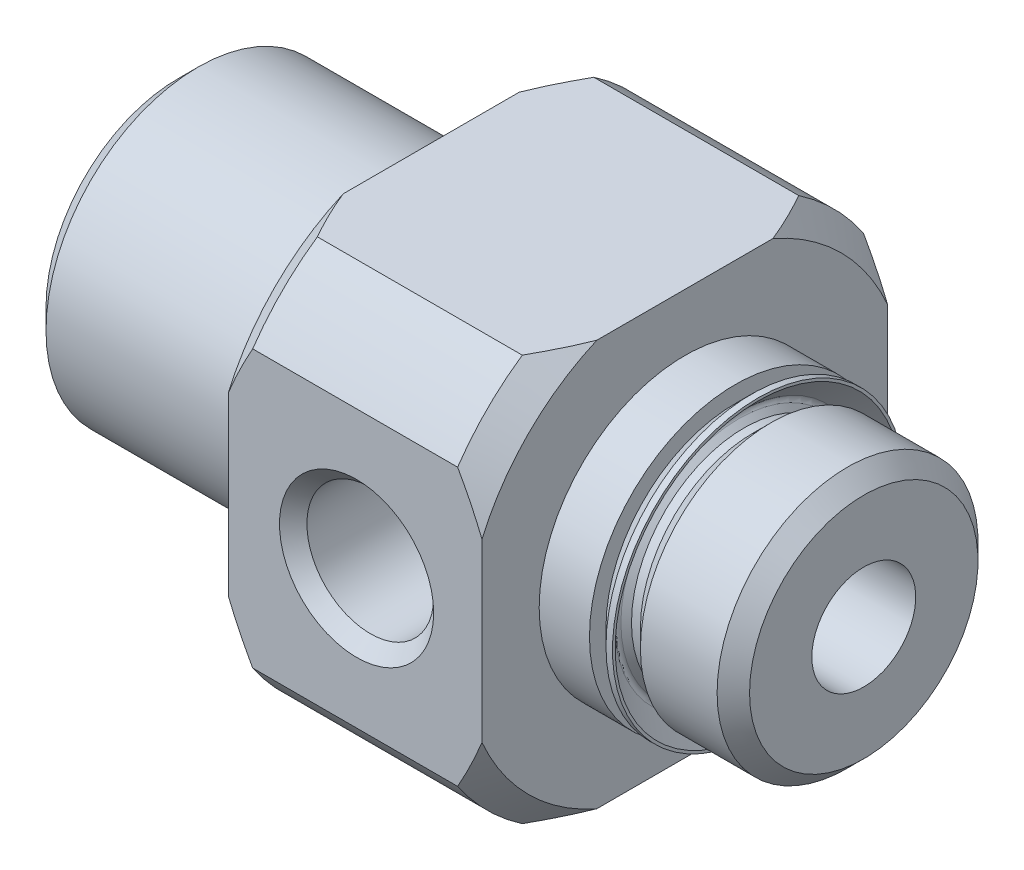
from build123d import *

# Parameters (mm, degrees)
SKETCH3_W          = 1.5748
SKETCH3_H          = 4.5593
HOLE1_D            = 3.2512
HOLE1_DEPTH        = 21.463
HOLE1_CSINK_D      = 4.0132
HOLE1_CSINK_ANGLE  = 90
SKETCH6_W          = 25.4
SKETCH6_H          = 25.4
SKETCH6_W_2        = 12.7
SKETCH6_H_2        = 12.7
CUT_EXTRUDE1_DEPTH = 21.463
HOLE2_D            = 3.96748
HOLE2_DEPTH        = 6.35
HOLE2_CSINK_D      = 4.826
HOLE2_CSINK_ANGLE  = 90


with BuildPart() as part:
    # Sketch1 → Revolve1 (revolve)
    with BuildSketch(Plane.XY):
        Polygon((0, 0), (0, 4.13258), (0.62992, 4.7625), (7.9248, 4.7625), (7.9248, 0), align=None)
    revolve(axis=Axis((7.9248, 0, 0), (-1, 0, 0)))

    # Sketch2 → Revolve2 (revolve)
    with BuildSketch(Plane.XY):
        Polygon((7.9248, 0), (7.9248, 6.9215), (8.6868, 7.6835), (15.1003, 7.6835), (15.8623, 6.9215), (15.8623, 3.52425), (17.9959, 3.52425), (18.5547, 4.08305), (20.955, 4.08305), (21.463, 3.57505), (21.463, 0), align=None)
    revolve(axis=Axis((21.463, 0, 0), (-1, 0, 0)))

    # Sketch3 → Revolve3 (revolve)
    with BuildSketch(Plane.XY):
        with Locations((16.6497, 2.27965)):
            Rectangle(SKETCH3_W, SKETCH3_H)
    revolve(axis=Axis((17.4371, 0, 0), (-1, 0, 0)))

    # Hole1
    with Locations(Plane.ZY):
        with Locations((0, 0)):
            CounterSinkHole(HOLE1_D / 2, HOLE1_CSINK_D / 2, depth=HOLE1_DEPTH, counter_sink_angle=HOLE1_CSINK_ANGLE)

    # Sketch6 → Cut-Extrude1 (cut)
    with BuildSketch(Plane(origin=(0, 0, 0), x_dir=(0, 0, -1), z_dir=(1, 0, 0))):
        Rectangle(SKETCH6_W, SKETCH6_H)
        Rectangle(SKETCH6_W_2, SKETCH6_H_2, mode=Mode.SUBTRACT)
    extrude(amount=CUT_EXTRUDE1_DEPTH, mode=Mode.SUBTRACT)

    # Hole2
    with Locations(Plane.XY.offset(6.35)):
        with Locations((11.938, 0)):
            CounterSinkHole(HOLE2_D / 2, HOLE2_CSINK_D / 2, depth=HOLE2_DEPTH, counter_sink_angle=HOLE2_CSINK_ANGLE)

    # Sketch9 → Revolve4 (revolve)
    with BuildSketch(Plane.XY):
        with BuildLine():
            Line((17.4371, 3.27025), (17.9959, 3.27025))
            Line((17.9959, 3.27025), (17.9959, 3.52425))
            Line((17.9959, 3.52425), (17.7165, 3.52425))
            Line((17.7165, 3.52425), (17.550871292, 3.689878708))
            ThreePointArc((17.550871292, 3.689878708), (17.513673853, 3.779681269), (17.550871292, 3.869483831))
            Line((17.550871292, 3.869483831), (18.156519265, 4.475131804))
            Line((18.156519265, 4.475131804), (18.156519265, 4.5593))
            Line((18.156519265, 4.5593), (17.953319265, 4.5593))
            Line((17.953319265, 4.5593), (17.4371, 4.043080735))
            Line((17.4371, 4.043080735), (17.4371, 3.27025))
        make_face()
    revolve(axis=Axis((17.9959, 0, 0), (-1, 0, 0)))


solid = part.part
